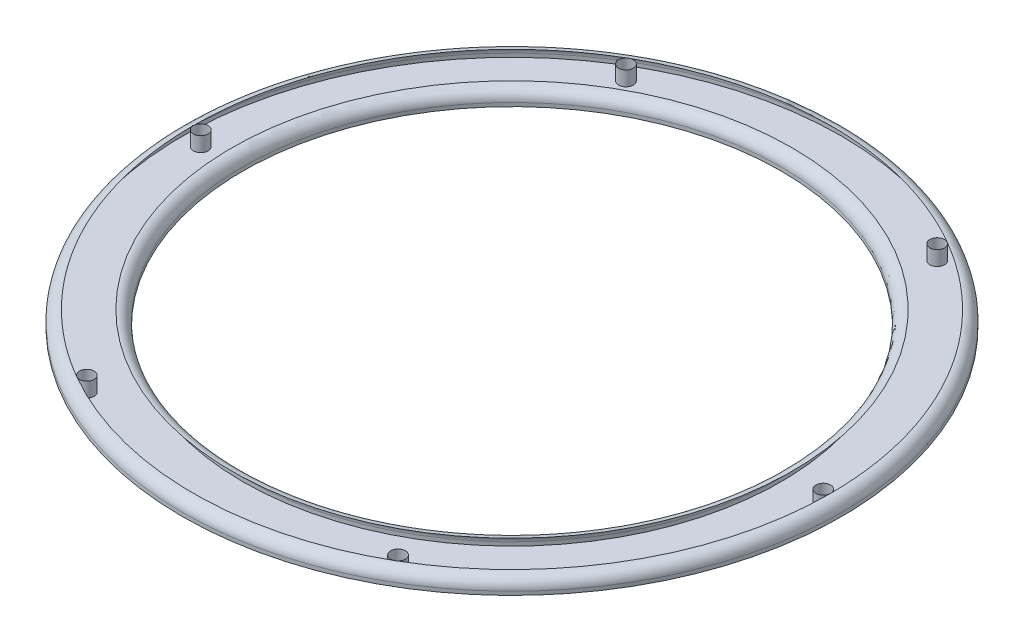
from build123d import *

# Parameters (mm, degrees)
SKETCH2_R          = 2
CUT_EXTRUDE1_DEPTH = 5
CIRPATTERN1_COUNT  = 6


with BuildPart() as part:
    # Sketch1 → Revolve1 (revolve)
    with BuildSketch(Plane.XY):
        with BuildLine():
            Line((-73.5, 0), (-90, 0))
            Line((-90, 0), (-90, 1))
            ThreePointArc((-90, 1), (-89.121320344, 3.121320344), (-87, 4))
            Line((-87, 4), (-76.5, 4))
            ThreePointArc((-76.5, 4), (-74.378679656, 3.121320344), (-73.5, 1))
            Line((-73.5, 1), (-73.5, 0))
        make_face()
    revolve(axis=Axis((0, 0, 0), (0, 1, 0)))

    # Sketch2 → Cut-Extrude1 (cut, through all)
    with BuildSketch(Plane(origin=(0, 4, 0), x_dir=(1, 0, 0), z_dir=(0, 1, 0))):
        with Locations((-85, 0)):
            Circle(SKETCH2_R)
    cut_extrude1 = extrude(amount=-CUT_EXTRUDE1_DEPTH, mode=Mode.SUBTRACT)

    # CirPattern1: Cut-Extrude1 ×6 about axis
    cirpattern1_axis = Axis((0, 0, 0), (0, 1, 0))
    for i in range(1, CIRPATTERN1_COUNT):
        add(cut_extrude1.rotate(cirpattern1_axis, i * 360 / CIRPATTERN1_COUNT), mode=Mode.SUBTRACT)


solid = part.part
